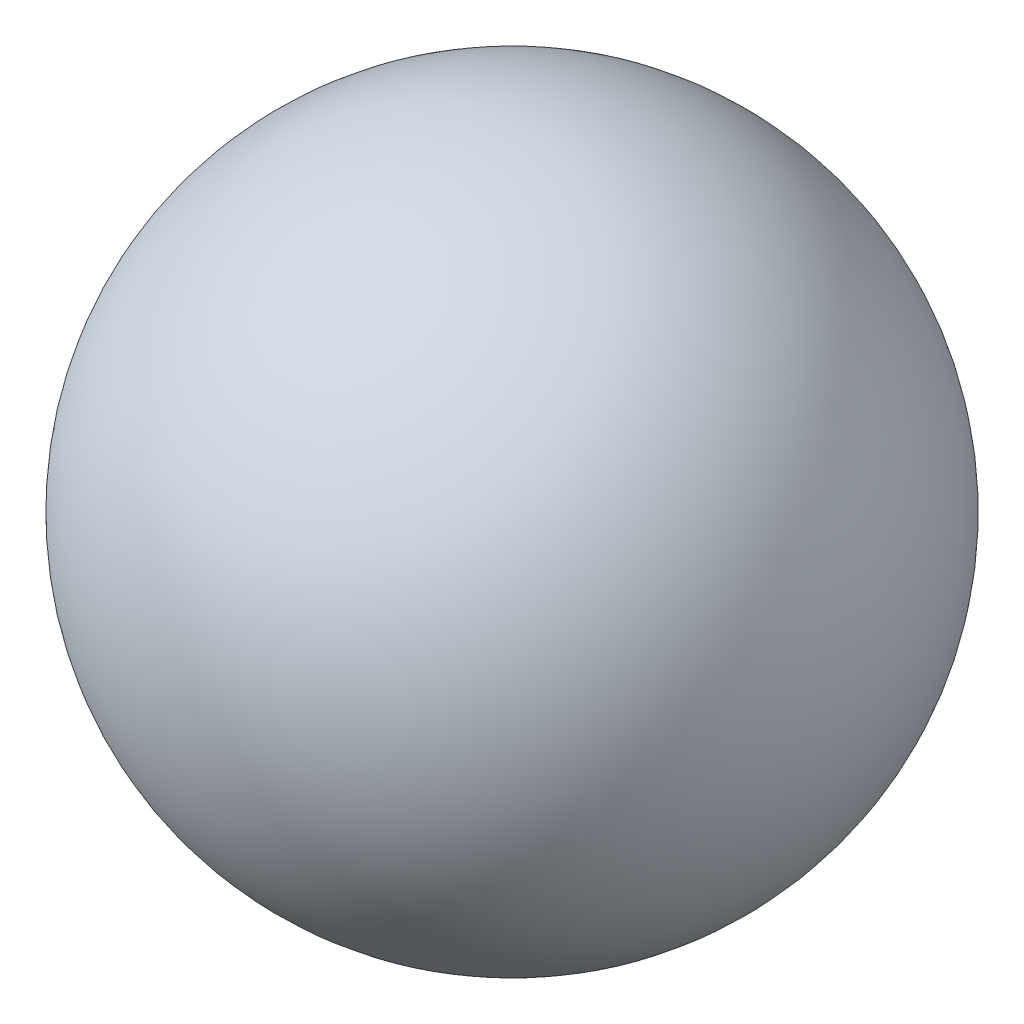
from build123d import *


with BuildPart() as part:
    # Sketch2 → Revolve7 (revolve)
    with BuildSketch(Plane.XY):
        with BuildLine():
            Line((0, 367.6), (0, -367.6))
            ThreePointArc((0, -367.6), (367.6, 0), (0, 367.6))
        make_face()
    revolve(axis=Axis((0, 367.6, 0), (0, -1, 0)))


solid = part.part
